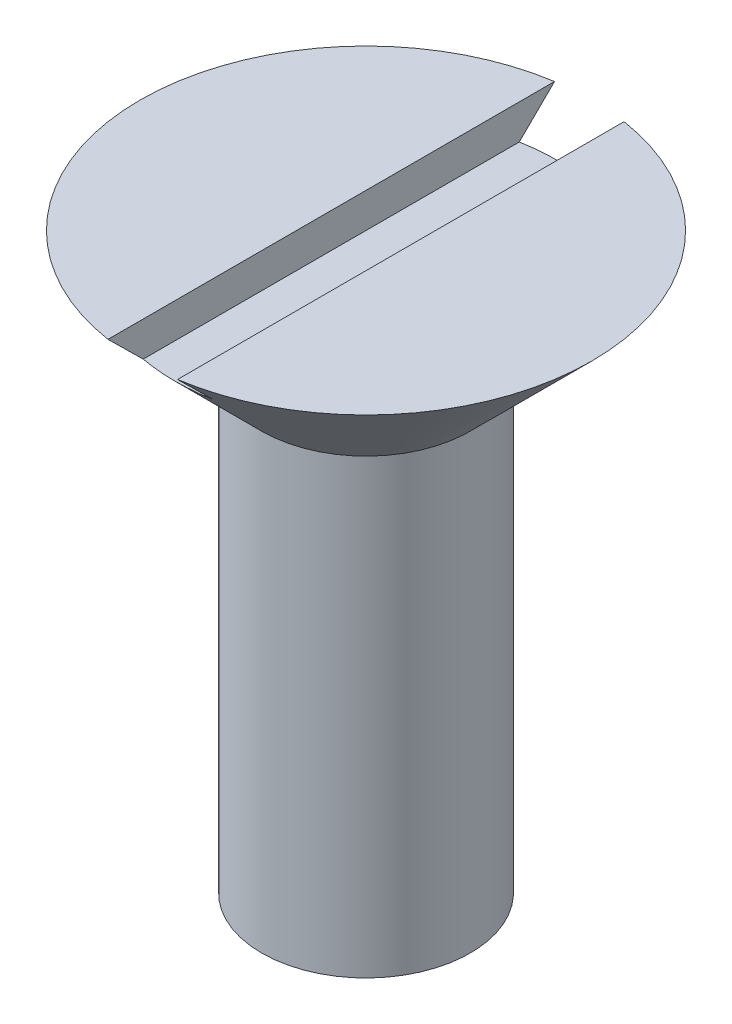
from build123d import *

# Parameters (mm, degrees)
SKETCH2_W               = 2
SKETCH2_H               = 2
CUT_EXTRUDE1_DEPTH      = 7.5
CUT_EXTRUDE1_DEPTH_BACK = 7.5


with BuildPart() as part:
    # Sketch1 → Revolve1 (revolve)
    with BuildSketch(Plane.XY):
        Polygon((3, 1.732050808), (0, 0), (0, 18.232050808), (6.5, 18.232050808), (3, 14.732050808), align=None)
    revolve(axis=Axis((0, 18.232050808, 0), (0, -1, 0)))

    # Sketch2 → Cut-Extrude1 (cut, two sides)
    with BuildSketch(Plane.XY) as cut_extrude1_sk:
        with Locations((0, 18.232050808)):
            Rectangle(SKETCH2_W, SKETCH2_H)
    extrude(amount=CUT_EXTRUDE1_DEPTH, mode=Mode.SUBTRACT)
    extrude(cut_extrude1_sk.sketch, amount=-CUT_EXTRUDE1_DEPTH_BACK, mode=Mode.SUBTRACT)


solid = part.part
